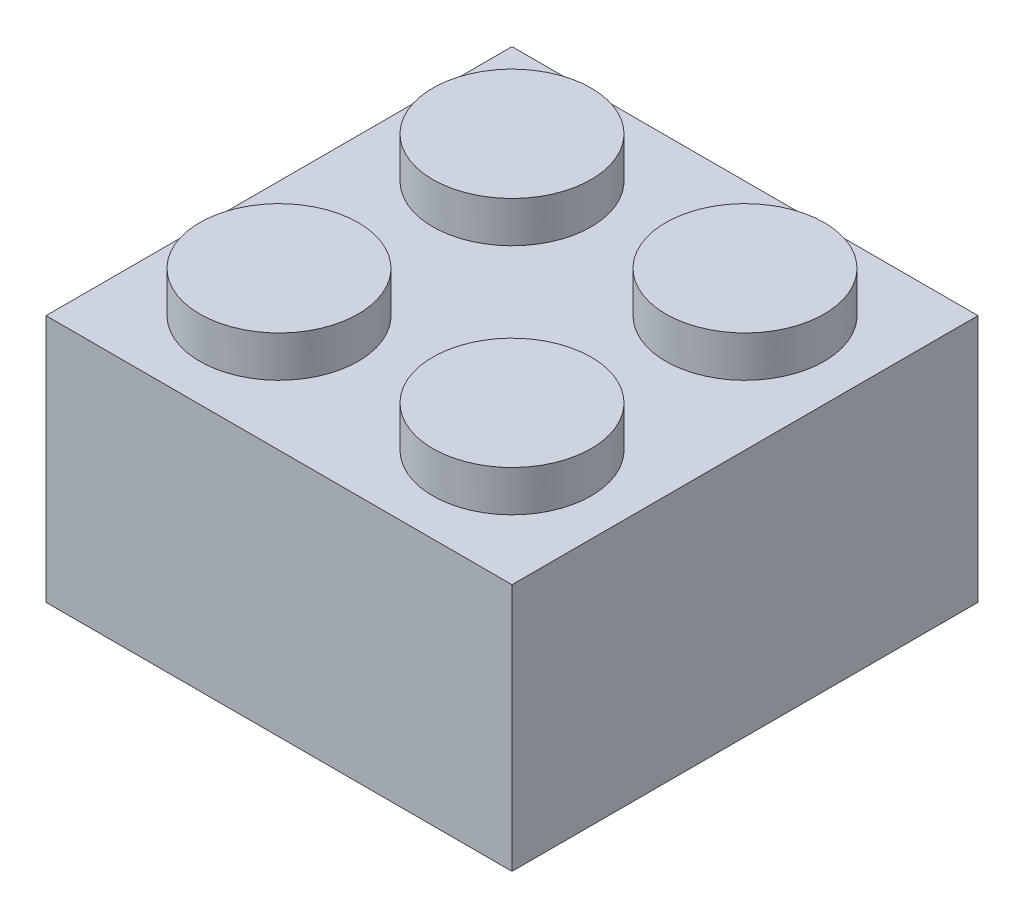
from build123d import *

# Parameters (mm, degrees)
SKETCH1_W            = 15.875
SKETCH1_H            = 15.875
BOSS_EXTRUDE1_DEPTH  = 4.2291
SKETCH2_W            = 13.335
SKETCH2_H            = 13.335
SKETCH2_R            = 3.175
SKETCH2_R_2          = 2.413
CUT_EXTRUDE1_DEPTH   = 7.1882
SKETCH3_R            = 2.69875
BOSS_EXTRUDE2_DEPTH  = 1.397
LPATTERN1_COUNT      = 2
LPATTERN1_PITCH      = 7.9375
LPATTERN1_COUNT_DIR2 = 2
LPATTERN1_PITCH_DIR2 = 7.9375


with BuildPart() as part:
    # Sketch1 → Boss-Extrude1 (new body, symmetric)
    with BuildSketch(Plane(origin=(0, 0, 0), x_dir=(1, 0, 0), z_dir=(0, 1, 0))):
        Rectangle(SKETCH1_W, SKETCH1_H)
    extrude(amount=BOSS_EXTRUDE1_DEPTH, both=True)

    # Sketch2 → Cut-Extrude1 (cut)
    with BuildSketch(Plane.XZ.offset(4.2291)):
        Rectangle(SKETCH2_W, SKETCH2_H)
        Circle(SKETCH2_R, mode=Mode.SUBTRACT)
        Circle(SKETCH2_R_2)
    extrude(amount=-CUT_EXTRUDE1_DEPTH, mode=Mode.SUBTRACT)

    # Sketch3 → Boss-Extrude2 (add)
    with BuildSketch(Plane(origin=(0, 4.2291, 0), x_dir=(1, 0, 0), z_dir=(0, 1, 0))):
        with Locations((3.96875, -3.96875)):
            Circle(SKETCH3_R)
    boss_extrude2 = extrude(amount=BOSS_EXTRUDE2_DEPTH)

    # LPattern1: Boss-Extrude2 2 × 2
    with Locations(*[(-i * LPATTERN1_PITCH, 0, -j * LPATTERN1_PITCH_DIR2) for i in range(LPATTERN1_COUNT) for j in range(LPATTERN1_COUNT_DIR2) if (i, j) != (0, 0)]):
        add(boss_extrude2)


solid = part.part
